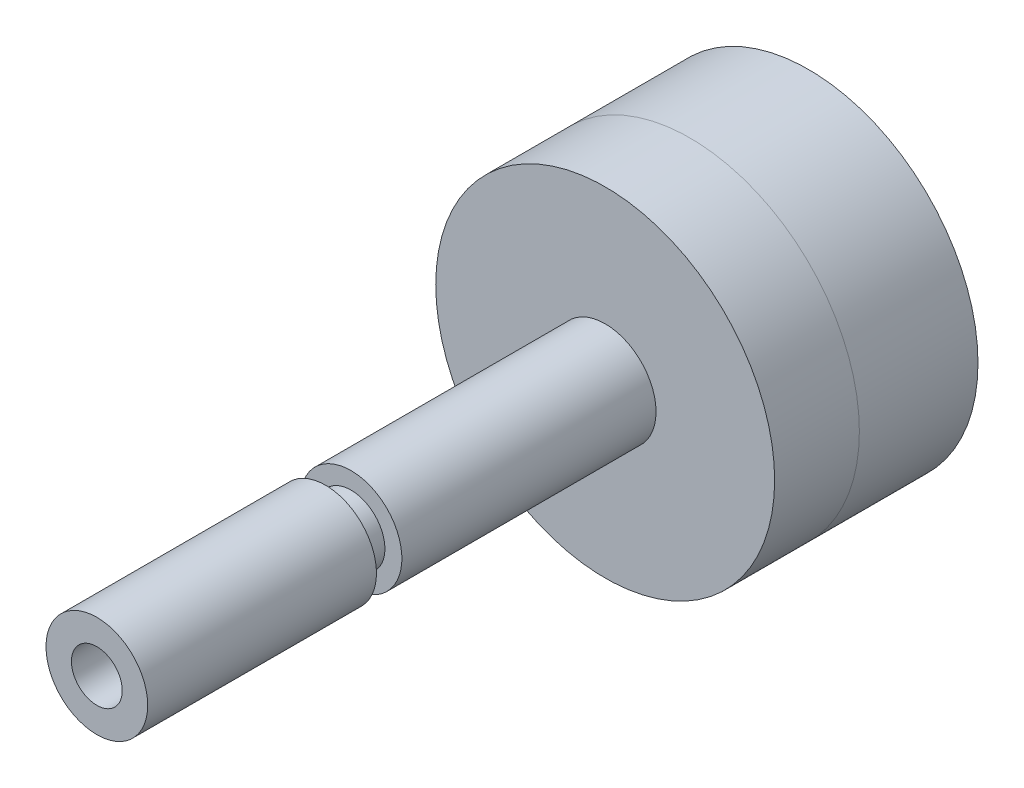
from build123d import *

# Parameters (mm, degrees)
CROQUIS1_R              = 10
SALIENTE_EXTRUIR1_DEPTH = 5
CROQUIS1_6_R            = 3
CROQUIS1_6_R_2          = 1.5
EXTRUIR_L_MINA1_DEPTH   = 35
CROQUIS2_W              = 1
CROQUIS2_H              = 1.5
CROQUIS1_7_R            = 10
CROQUIS1_7_R_2          = 9
EXTRUIR_L_MINA2_DEPTH   = 7


with BuildPart() as part:
    # Croquis1 → Saliente-Extruir1 (new body)
    with BuildSketch(Plane.XY):
        Circle(CROQUIS1_R)
    extrude(amount=SALIENTE_EXTRUIR1_DEPTH)

    # Croquis1_6 → Extruir-L_mina1 (add)
    with BuildSketch(Plane.XY):
        Circle(CROQUIS1_6_R)
        Circle(CROQUIS1_6_R_2, mode=Mode.SUBTRACT)
    extrude(amount=EXTRUIR_L_MINA1_DEPTH)

    # Croquis2 → Cortar-Revoluci_n2 (revolve, cut)
    with BuildSketch(Plane(origin=(0, 0, 0), x_dir=(1, 0, 0), z_dir=(0, 1, 0))):
        with Locations((-2.5, -20.75)):
            Rectangle(CROQUIS2_W, CROQUIS2_H)
    revolve(axis=Axis((0, 0, 0), (0, 0, 1)), mode=Mode.SUBTRACT)


with BuildPart() as body_2:
    # Croquis1_7 → Extruir-L_mina2 (new body)
    with BuildSketch(Plane.XY):
        Circle(CROQUIS1_7_R)
        Circle(CROQUIS1_7_R_2, mode=Mode.SUBTRACT)
    extrude(amount=-EXTRUIR_L_MINA2_DEPTH)


solid = Compound([part.part, body_2.part])
